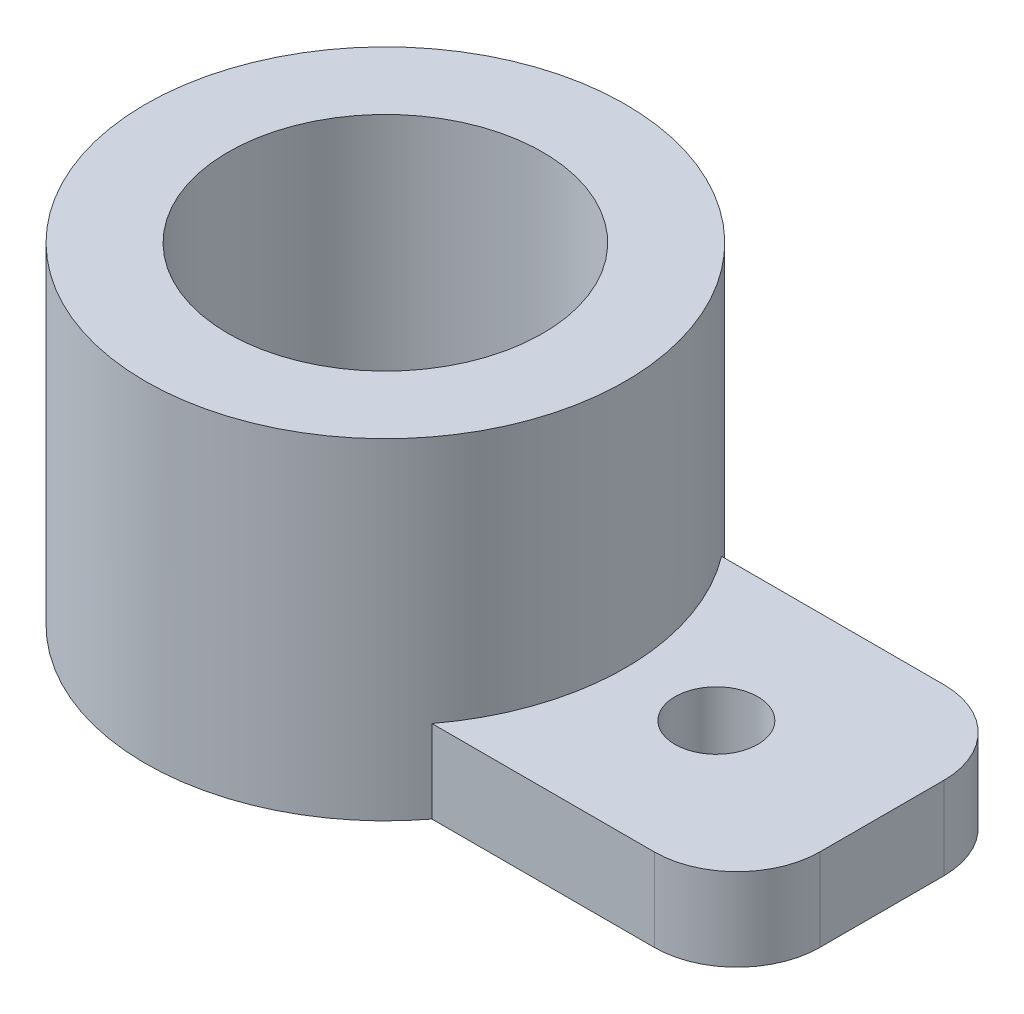
from build123d import *

# Parameters (mm, degrees)
SKETCH_1_R          = 2.9
EXTRUDE_1_DEPTH     = 4
SKETCH_2_W          = 12.628096459
SKETCH_2_H          = 3.5
EXTRUDE_2_DEPTH     = 1
SKETCH_3_R          = 0.5
SKETCH_3_R_2        = 1
CUT_EXTRUDE_1_DEPTH = 5
FILLET_1_R          = 1.5
SKETCH_4_R          = 1.9
CUT_EXTRUDE_2_DEPTH = 3
SKETCH_5_W          = 9.116647883
SKETCH_5_H          = 3.5
CUT_EXTRUDE_3_DEPTH = 2
FILLET_2_R          = 1


with BuildPart() as part:
    # 草图1 → 凸台-拉伸1 (new body)
    with BuildSketch(Plane(origin=(0, 0, 0), x_dir=(1, 0, 0), z_dir=(0, 1, 0))):
        Circle(SKETCH_1_R)
    extrude(amount=EXTRUDE_1_DEPTH)

    # 草图2 → 凸台-拉伸2 (add)
    with BuildSketch(Plane(origin=(0, 0, 0), x_dir=(1, 0, 0), z_dir=(0, 1, 0))):
        with Locations((7.685951771, 0)):
            Rectangle(SKETCH_2_W, SKETCH_2_H)
    extrude(amount=EXTRUDE_2_DEPTH)

    # 草图3 → 切除-拉伸1 (cut, through all)
    with BuildSketch(Plane(origin=(0, 0, 0), x_dir=(1, 0, 0), z_dir=(0, 1, 0))):
        with Locations((8, 0)):
            Circle(SKETCH_3_R)
        with Locations((12, 0)):
            Circle(SKETCH_3_R)
        with Locations((10, 0)):
            Circle(SKETCH_3_R)
        Circle(SKETCH_3_R_2)
        with Locations((4, 0)):
            Circle(SKETCH_3_R)
    extrude(amount=CUT_EXTRUDE_1_DEPTH, mode=Mode.SUBTRACT)

    # 圆角1
    fillet_1_edges = [part.edges().sort_by_distance(p)[0] for p in [
        (14, 0.5, -1.75),
        (14, 0.5, 1.75),
    ]]
    fillet(fillet_1_edges, radius=FILLET_1_R)

    # 草图4 → 切除-拉伸2 (cut)
    with BuildSketch(Plane(origin=(0, 4, 0), x_dir=(1, 0, 0), z_dir=(0, 1, 0))):
        Circle(SKETCH_4_R)
    extrude(amount=-CUT_EXTRUDE_2_DEPTH, mode=Mode.SUBTRACT)

    # 草图5 → 切除-拉伸3 (cut, through all)
    with BuildSketch(Plane(origin=(0, 1, 0), x_dir=(1, 0, 0), z_dir=(0, 1, 0))):
        with Locations((10.558323941, 0)):
            Rectangle(SKETCH_5_W, SKETCH_5_H)
    extrude(amount=-CUT_EXTRUDE_3_DEPTH, mode=Mode.SUBTRACT)

    # 圆角2
    fillet_2_edges = [part.edges().sort_by_distance(p)[0] for p in [
        (6, 0.5, 1.75),
        (6, 0.5, -1.75),
    ]]
    fillet(fillet_2_edges, radius=FILLET_2_R)


solid = part.part
